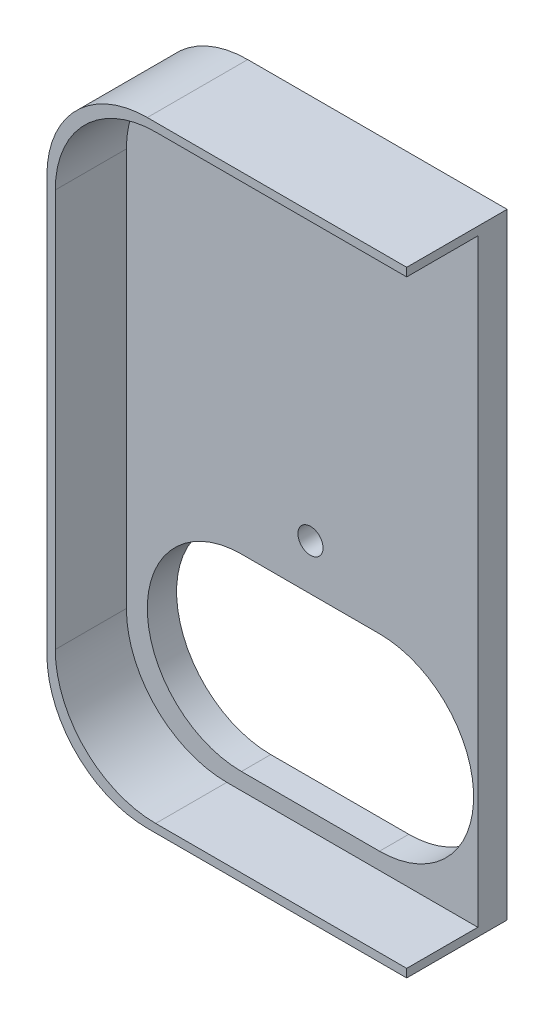
from build123d import *

# Parameters (mm, degrees)
BOSS_EXTRUDE2_DEPTH = 12
CUT_EXTRUDE1_DEPTH  = 8.5
SKETCH6_R           = 1.5
CUT_EXTRUDE2_DEPTH  = 8.5


with BuildPart() as part:
    # Sketch2 → Boss-Extrude2 (new body)
    with BuildSketch(Plane(origin=(0, 0, 0), x_dir=(0, 1, 0), z_dir=(0, 0, 1))):
        with BuildLine():
            Line((-36.78, -21.5), (36.78, -21.5))
            Line((36.78, -21.5), (36.78, 9.5))
            ThreePointArc((36.78, 9.5), (33.265281374, 17.985281374), (24.78, 21.5))
            Line((24.78, 21.5), (-24.78, 21.5))
            ThreePointArc((-24.78, 21.5), (-33.265281374, 17.985281374), (-36.78, 9.5))
            Line((-36.78, 9.5), (-36.78, -21.5))
        make_face()
    extrude(amount=BOSS_EXTRUDE2_DEPTH)

    # Sketch5 → Cut-Extrude1 (cut)
    with BuildSketch(Plane.XY.offset(12)):
        with BuildLine():
            Line((21.5, -35.78), (-8.5, -35.78))
            ThreePointArc((-8.5, -35.78), (-16.985281374, -32.265281374), (-20.5, -23.78))
            Line((-20.5, -23.78), (-20.5, 23.78))
            ThreePointArc((-20.5, 23.78), (-16.985281374, 32.265281374), (-8.5, 35.78))
            Line((-8.5, 35.78), (21.5, 35.78))
            Line((21.5, 35.78), (21.5, -35.78))
        make_face()
    extrude(amount=-CUT_EXTRUDE1_DEPTH, mode=Mode.SUBTRACT)

    # Sketch6 → Cut-Extrude2 (cut)
    with BuildSketch(Plane.XY.offset(3.5)):
        with Locations((1.5, -5.78)):
            Circle(SKETCH6_R)
        with BuildLine():
            Line((9.75, -33.78), (-6.75, -33.78))
            ThreePointArc((-6.75, -33.78), (-18, -22.53), (-6.75, -11.28))
            Line((-6.75, -11.28), (9.75, -11.28))
            ThreePointArc((9.75, -11.28), (21, -22.53), (9.75, -33.78))
        make_face()
    extrude(amount=-CUT_EXTRUDE2_DEPTH, mode=Mode.SUBTRACT)


solid = part.part
